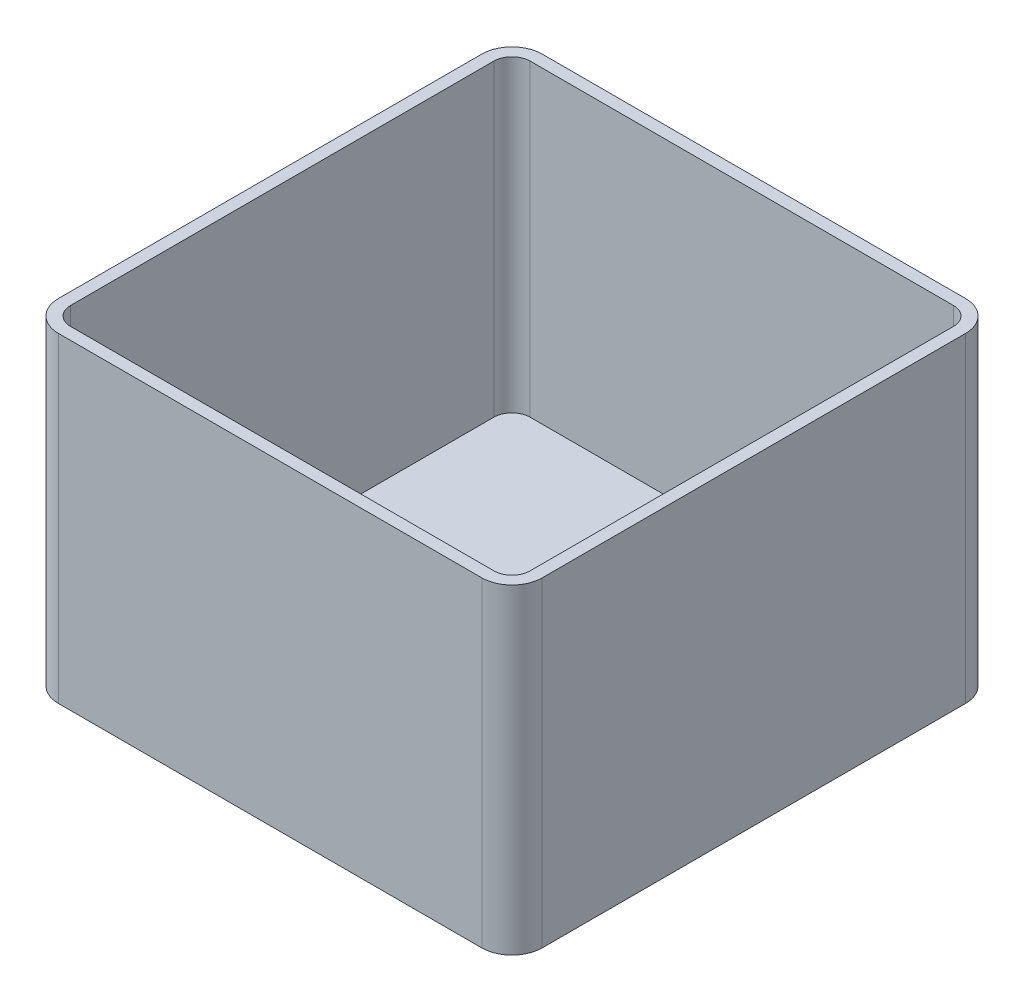
from build123d import *

# Parameters (mm, degrees)
ESQUISSE1_W      = 80
ESQUISSE1_H      = 80
EXTRUSION1_DEPTH = 53
CONG_1_R         = 5
COQUE1_T         = -2


with BuildPart() as part:
    # Esquisse1 → Extrusion1 (new body)
    with BuildSketch(Plane(origin=(0, 0, 0), x_dir=(1, 0, 0), z_dir=(0, 1, 0))):
        with Locations((40, 40)):
            Rectangle(ESQUISSE1_W, ESQUISSE1_H)
    extrude(amount=EXTRUSION1_DEPTH)

    # Congé1
    cong_1_edges = [part.edges().sort_by_distance(p)[0] for p in [
        (0, 26.5, -80),
        (80, 26.5, -80),
        (80, 26.5, 0),
        (0, 26.5, 0),
    ]]
    fillet(cong_1_edges, radius=CONG_1_R)

    # Coque1
    coque1_openings = [part.faces().sort_by_distance(p)[0] for p in [
        (40, 53, -40),
    ]]
    offset(amount=COQUE1_T, openings=coque1_openings, kind=Kind.INTERSECTION)


solid = part.part
